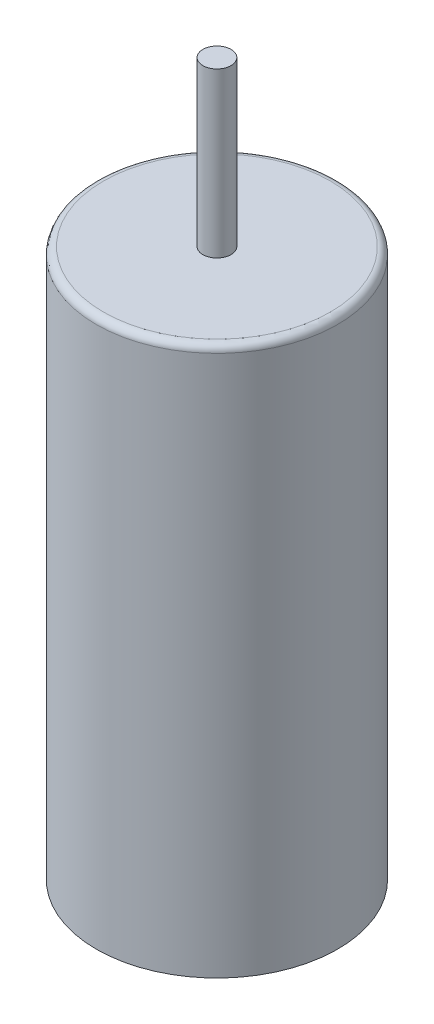
from build123d import *

# Parameters (mm, degrees)
SKETCH1_R           = 4.25
BOSS_EXTRUDE1_DEPTH = 9.652
SKETCH2_R           = 0.4953
BOSS_EXTRUDE2_DEPTH = 5.7658
FILLET1_R           = 0.254


with BuildPart() as part:
    # Sketch1 → Boss-Extrude1 (new body, symmetric)
    with BuildSketch(Plane(origin=(0, 0, 0), x_dir=(1, 0, 0), z_dir=(0, 1, 0))):
        Circle(SKETCH1_R)
    extrude(amount=BOSS_EXTRUDE1_DEPTH, both=True)

    # Sketch2 → Boss-Extrude2 (add)
    with BuildSketch(Plane(origin=(0, 9.652, 0), x_dir=(1, 0, 0), z_dir=(0, 1, 0))):
        Circle(SKETCH2_R)
    extrude(amount=BOSS_EXTRUDE2_DEPTH)

    # Fillet1
    fillet1_edges = [part.edges().sort_by_distance(p)[0] for p in [
        (-4.25, 9.652, 0),
    ]]
    fillet(fillet1_edges, radius=FILLET1_R)


solid = part.part
